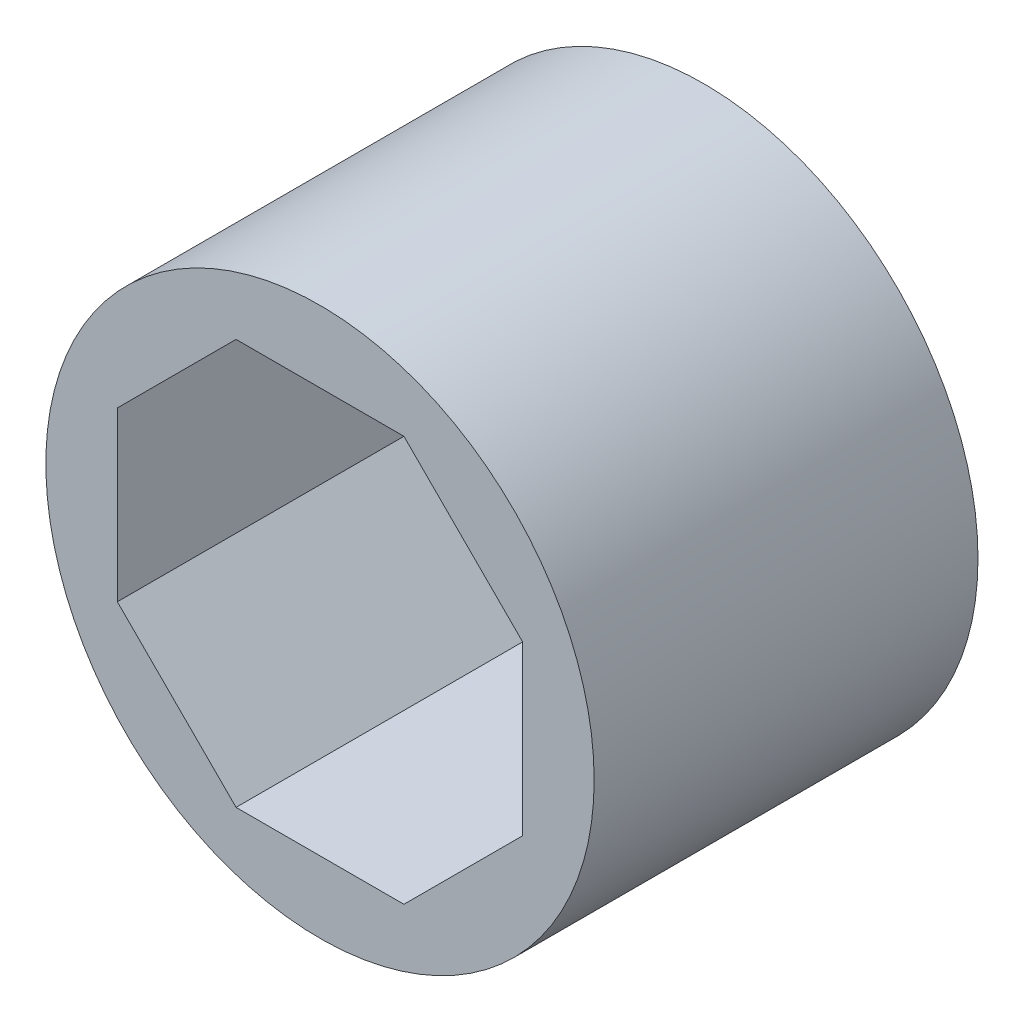
from build123d import *

# Parameters (mm, degrees)
SKETCH2_R           = 5
BOSS_EXTRUDE1_DEPTH = 7


with BuildPart() as part:
    # Sketch2 → Boss-Extrude1 (new body)
    with BuildSketch(Plane.XY):
        Circle(SKETCH2_R)
        Polygon((1.530733729, 3.69551813), (-1.530733729, 3.69551813), (-3.69551813, 1.530733729), (-3.69551813, -1.530733729), (-1.530733729, -3.69551813), (1.530733729, -3.69551813), (3.69551813, -1.530733729), (3.69551813, 1.530733729), align=None, mode=Mode.SUBTRACT)
    extrude(amount=BOSS_EXTRUDE1_DEPTH)


solid = part.part
